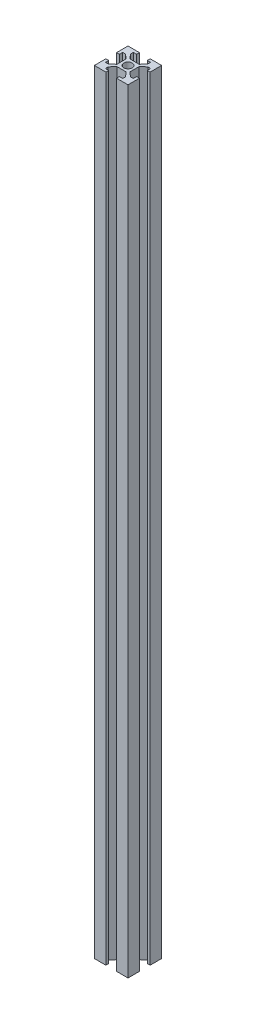
from build123d import *

# Parameters (mm, degrees)
SKETCH_1_W          = 20
SKETCH_1_H          = 20
EXTRUDE_1_DEPTH     = 460
SKETCH_2_R          = 2.5
CUT_EXTRUDE_1_DEPTH = 461


with BuildPart() as part:
    # 草图1 → 凸台-拉伸1 (new body)
    with BuildSketch(Plane(origin=(0, 0, 0), x_dir=(1, 0, 0), z_dir=(0, 1, 0))):
        Rectangle(SKETCH_1_W, SKETCH_1_H)
    extrude(amount=EXTRUDE_1_DEPTH)

    # 草图2 → 切除-拉伸1 (cut, through all)
    with BuildSketch(Plane(origin=(0, 460, 0), x_dir=(1, 0, 0), z_dir=(0, 1, 0))):
        Circle(SKETCH_2_R)
        Polygon((-3.15, 10), (-3.15, 8.3), (-5.15, 8.3), (-5.15, 6.6), (-2.75, 3.9), (2.75, 3.9), (5.15, 6.6), (5.15, 8.3), (3.15, 8.3), (3.15, 10), align=None)
        Polygon((3.9, 2.75), (3.9, -2.75), (6.6, -5.15), (8.3, -5.15), (8.3, -3.15), (10, -3.15), (10, 3.15), (8.3, 3.15), (8.3, 5.15), (6.6, 5.15), align=None)
        Polygon((2.75, -3.9), (-2.75, -3.9), (-5.15, -6.6), (-5.15, -8.3), (-3.15, -8.3), (-3.15, -10), (3.15, -10), (3.15, -8.3), (5.15, -8.3), (5.15, -6.6), align=None)
        Polygon((-3.9, -2.75), (-3.9, 2.75), (-6.6, 5.15), (-8.3, 5.15), (-8.3, 3.15), (-10, 3.15), (-10, -3.15), (-8.3, -3.15), (-8.3, -5.15), (-6.6, -5.15), align=None)
    extrude(amount=-CUT_EXTRUDE_1_DEPTH, mode=Mode.SUBTRACT)


solid = part.part
